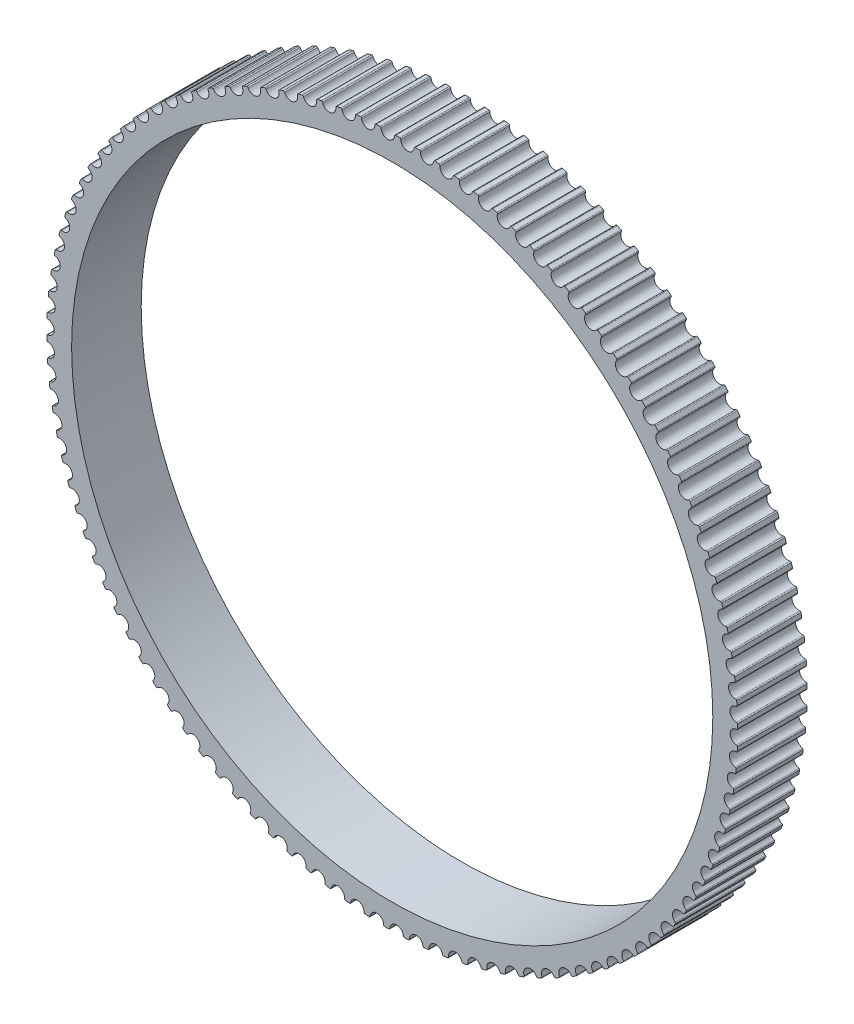
from build123d import *

# Parameters (mm, degrees)
BOSS_EXTRUDE1_DEPTH = 3.5
SKETCH4_R           = 32.25
CUT_EXTRUDE2_DEPTH  = 3.5


with BuildPart() as part:
    # Sketch2 → Boss-Extrude1 (new body, symmetric)
    with BuildSketch(Plane.XY):
        with BuildLine():
            ThreePointArc((-3.211333328, 34.601298216), (-3.132582306, 34.577768977), (-3.092122191, 34.506226488))
            ThreePointArc((-3.092122191, 34.506226488), (-2.370608918, 33.917255392), (-1.738041502, 34.600868455))
            ThreePointArc((-1.738041502, 34.600868455), (-1.707926922, 34.677343683), (-1.633214692, 34.711599067))
            ThreePointArc((-1.633214692, 34.711599067), (-1.432005901, 34.720481839), (-1.230749008, 34.728198296))
            ThreePointArc((-1.230749008, 34.728198296), (-1.153469677, 34.700211628), (-1.117159824, 34.626475997))
            ThreePointArc((-1.117159824, 34.626475997), (-0.430446923, 33.997275118), (0.240115498, 34.643660757))
            ThreePointArc((0.240115498, 34.643660757), (0.274546844, 34.718292057), (0.351092826, 34.748226341))
            ThreePointArc((0.351092826, 34.748226341), (0.552480572, 34.745607855), (0.75384976, 34.741822211))
            ThreePointArc((0.75384976, 34.741822211), (0.829405331, 34.709469401), (0.861446487, 34.63378114))
            ThreePointArc((0.861446487, 34.63378114), (1.5111191, 33.966402798), (2.217489291, 34.573452638))
            ThreePointArc((2.217489291, 34.573452638), (2.256125096, 34.645996578), (2.334255151, 34.671512123))
            ThreePointArc((2.334255151, 34.671512123), (2.535164969, 34.657400921), (2.735989626, 34.642125523))
            ThreePointArc((2.735989626, 34.642125523), (2.809574991, 34.6055121), (2.837242938, 34.528118086))
            ThreePointArc((2.837242938, 34.528118086), (3.447756167, 33.824739133), (4.187630095, 34.390473103))
            ThreePointArc((4.187630095, 34.390473103), (4.230344336, 34.460693059), (4.309803622, 34.481706639))
            ThreePointArc((4.309803622, 34.481706639), (4.509580184, 34.456148748), (4.709205264, 34.429433422))
            ThreePointArc((4.709205264, 34.429433422), (4.780580401, 34.388678811), (4.803784892, 34.309831489))
            ThreePointArc((4.803784892, 34.309831489), (5.373147369, 33.572746199), (6.14411172, 34.095318993))
            ThreePointArc((6.14411172, 34.095318993), (6.190765072, 34.162985922), (6.271294408, 34.179428995))
            ThreePointArc((6.271294408, 34.179428995), (6.469286087, 34.14250778), (6.667060452, 34.104439666))
            ThreePointArc((6.667060452, 34.104439666), (6.735992552, 34.059676799), (6.754657899, 33.979633352))
            ThreePointArc((6.754657899, 33.979633352), (7.281012482, 33.211245945), (8.080552529, 33.68895304))
            ThreePointArc((8.080552529, 33.68895304), (8.13099282, 33.753846226), (8.212329536, 33.765665158))
            ThreePointArc((8.212329536, 33.765665158), (8.407890523, 33.717501049), (8.603169075, 33.668204316))
            ThreePointArc((8.603169075, 33.668204316), (8.669433295, 33.619579201), (8.683498616, 33.538600714))
            ThreePointArc((8.683498616, 33.538600714), (9.165128446, 32.74141751), (9.990636256, 33.172700723))
            ThreePointArc((9.990636256, 33.172700723), (10.044698959, 33.2346085), (10.126577752, 33.24176474))
            ThreePointArc((10.126577752, 33.24176474), (10.319070167, 33.182514837), (10.511215949, 33.122150282))
            ThreePointArc((10.511215949, 33.122150282), (10.574596148, 33.069821524), (10.584015565, 32.988172132))
            ThreePointArc((10.584015565, 32.988172132), (11.019349666, 32.164793376), (11.868132604, 32.548245952))
            ThreePointArc((11.868132604, 32.548245952), (11.925641377, 32.606966388), (12.007795176, 32.609436594))
            ThreePointArc((12.007795176, 32.609436594), (12.196591149, 32.539294158), (12.384977421, 32.468058678))
            ThreePointArc((12.384977421, 32.468058678), (12.445266867, 32.412196962), (12.450009655, 32.330142989))
            ThreePointArc((12.450009655, 32.330142989), (12.837628057, 31.483254372), (13.70691757, 31.817625568))
            ThreePointArc((13.70691757, 31.817625568), (13.767684832, 31.87296713), (13.849845668, 31.870743245))
            ThreePointArc((13.849845668, 31.870743245), (14.034329387, 31.789937066), (14.21834167, 31.708063015))
            ThreePointArc((14.21834167, 31.708063015), (14.275343712, 31.648850551), (14.275394401, 31.566659639))
            ThreePointArc((14.275394401, 31.566659639), (14.614032774, 30.699023536), (15.50099342, 30.983222703))
            ThreePointArc((15.50099342, 30.983222703), (15.564820961, 31.035004878), (15.646720842, 31.028094155))
            ThreePointArc((15.646720842, 31.028094155), (15.826290558, 30.936887807), (16.005328645, 30.844642241))
            ThreePointArc((16.005328645, 30.844642241), (16.058857353, 30.782272168), (16.054215778, 30.700212407))
            ThreePointArc((16.054215778, 30.700212407), (16.342769554, 29.814658866), (17.244508252, 30.047759005))
            ThreePointArc((17.244508252, 30.047759005), (17.31118788, 30.09581289), (17.392559666, 30.084237871))
            ThreePointArc((17.392559666, 30.084237871), (17.56662966, 29.982928849), (17.740109564, 29.880612655))
            ThreePointArc((17.740109564, 29.880612655), (17.78999034, 29.815288411), (17.78067164, 29.733627463))
            ThreePointArc((17.78067164, 29.733627463), (18.018199616, 28.833044976), (18.931775082, 29.014285763))
            ThreePointArc((18.931775082, 29.014285763), (19.001089301, 29.058454616), (19.081667574, 29.042253056))
            ThreePointArc((19.081667574, 29.042253056), (19.249670067, 28.93117181), (19.417025934, 28.819118722))
            ThreePointArc((19.417025934, 28.819118722), (19.463096075, 28.75105338), (19.449130647, 28.670057606))
            ThreePointArc((19.449130647, 28.670057606), (19.634858056, 27.757383686), (20.557290396, 27.886173951))
            ThreePointArc((20.557290396, 27.886173951), (20.629013119, 27.926313703), (20.708535049, 27.905538449))
            ThreePointArc((20.708535049, 27.905538449), (20.869922051, 27.785047302), (21.030608, 27.663622813))
            ThreePointArc((21.030608, 27.663622813), (21.072717237, 27.59303839), (21.054150632, 27.512971981))
            ThreePointArc((21.054150632, 27.512971981), (21.187471671, 26.59118358), (22.115752103, 26.667103236))
            ThreePointArc((22.115752103, 26.667103236), (22.189649383, 26.70308296), (22.267855587, 26.677801775))
            ThreePointArc((22.267855587, 26.677801775), (22.422100687, 26.548293745), (22.575592595, 26.417893917))
            ThreePointArc((22.575592595, 26.417893917), (22.613603575, 26.345020643), (22.590496355, 26.26614476))
            ThreePointArc((22.590496355, 26.26614476), (22.670976156, 25.338248561), (23.602076822, 25.361049973))
            ThreePointArc((23.602076822, 25.361049973), (23.677907624, 25.39275231), (23.754543009, 25.363047657))
            ThreePointArc((23.754543009, 25.363047657), (23.901143092, 25.224945172), (24.046940299, 25.085995341))
            ThreePointArc((24.046940299, 25.085995341), (24.080729038, 25.011070915), (24.053156573, 24.933642834))
            ThreePointArc((24.053156573, 24.933642834), (24.08053263, 24.002665441), (25.011416473, 23.972274237))
            ThreePointArc((25.011416473, 23.972274237), (25.088933451, 23.99959578), (25.163748048, 23.965564549))
            ThreePointArc((25.163748048, 23.965564549), (25.302224935, 23.81931807), (25.439851882, 23.672271464))
            ThreePointArc((25.439851882, 23.672271464), (25.469308169, 23.595540272), (25.437360394, 23.519812547))
            ThreePointArc((25.437360394, 23.519812547), (25.411543411, 22.588790615), (26.339174082, 22.505305925))
            ThreePointArc((26.339174082, 22.505305925), (26.418124392, 22.528157557), (26.490874172, 22.489910751))
            ThreePointArc((26.490874172, 22.489910751), (26.62077618, 22.335997304), (26.749783955, 22.181333557))
            ThreePointArc((26.749783955, 22.181333557), (26.77481171, 22.103045881), (26.738592833, 22.029265521))
            ThreePointArc((26.738592833, 22.029265521), (26.65966702, 21.10123585), (27.58101878, 20.964929982))
            ThreePointArc((27.58101878, 20.964929982), (27.661144903, 20.983237166), (27.731592571, 20.940899539))
            ThreePointArc((27.731592571, 20.940899539), (27.852495986, 20.779821157), (27.972463794, 20.61804475))
            ThreePointArc((27.972463794, 20.61804475), (27.99298138, 20.538455949), (27.95260954, 20.466863609))
            ThreePointArc((27.95260954, 20.466863609), (27.820832336, 19.544853239), (28.732899927, 19.356170796))
            ThreePointArc((28.732899927, 19.356170796), (28.813940508, 19.369873818), (28.881856278, 19.323583465))
            ThreePointArc((28.881856278, 19.323583465), (28.99336674, 19.155865553), (29.103903269, 18.987504167))
            ThreePointArc((29.103903269, 18.987504167), (29.119843764, 18.906873842), (29.075450644, 18.837703042))
            ThreePointArc((29.075450644, 18.837703042), (28.89125188, 17.924719379), (29.791060327, 17.684275803))
            ThreePointArc((29.791060327, 17.684275803), (29.872751028, 17.693329967), (29.937913374, 17.643237878))
            ThreePointArc((29.937913374, 17.643237878), (30.039667157, 17.469427497), (30.140411862, 17.295030292))
            ThreePointArc((30.140411862, 17.295030292), (30.15172327, 17.213621443), (30.103453672, 17.147097804))
            ThreePointArc((30.103453672, 17.147097804), (29.867434165, 16.24611881), (30.75204848, 15.954698379))
            ThreePointArc((30.75204848, 15.954698379), (30.834122844, 15.959074151), (30.896319219, 15.905343716))
            ThreePointArc((30.896319219, 15.905343716), (30.987984424, 15.7260078), (31.078608696, 15.546143623))
            ThreePointArc((31.078608696, 15.546143623), (31.085254121, 15.464221788), (31.033265491, 15.400562296))
            ThreePointArc((31.033265491, 15.400562296), (30.746195088, 14.514526779), (31.612729843, 14.173080045))
            ThreePointArc((31.612729843, 14.173080045), (31.69492016, 14.172763152), (31.753947692, 14.115569629))
            ThreePointArc((31.753947692, 14.115569629), (31.835225327, 13.931293134), (31.915433568, 13.746548664))
            ThreePointArc((31.915433568, 13.746548664), (31.917391335, 13.664381057), (31.861853248, 13.603793356))
            ThreePointArc((31.861853248, 13.603793356), (31.524668313, 12.735591378), (32.370297052, 12.345232069))
            ThreePointArc((32.370297052, 12.345232069), (32.452335234, 12.340223546), (32.508001388, 12.279753488))
            ThreePointArc((32.508001388, 12.279753488), (32.578626342, 12.091137485), (32.648156929, 11.902115321))
            ThreePointArc((32.648156929, 11.902115321), (32.645420653, 11.819969954), (32.586514263, 11.762651669))
            ThreePointArc((32.586514263, 11.762651669), (32.200314623, 10.915115125), (33.02227908, 10.477116513))
            ThreePointArc((33.02227908, 10.477116513), (33.103897536, 10.467432696), (33.156020741, 10.403883344))
            ThreePointArc((33.156020741, 10.403883344), (33.215762649, 10.211543059), (33.274388789, 10.018859752))
            ThreePointArc((33.274388789, 10.018859752), (33.266967394, 9.937004566), (33.204884841, 9.883142657))
            ThreePointArc((33.204884841, 9.883142657), (32.770930199, 9.059036036), (33.566549298, 8.57482678))
            ThreePointArc((33.566549298, 8.57482678), (33.647481805, 8.560499256), (33.695892045, 8.494077894))
            ThreePointArc((33.695892045, 8.494077894), (33.744556042, 8.298640702), (33.792086508, 8.102924745))
            ThreePointArc((33.792086508, 8.102924745), (33.780004201, 8.021626735), (33.714947986, 7.971396888))
            ThreePointArc((33.714947986, 7.971396888), (33.234653812, 7.173408254), (34.001332409, 6.644567744))
            ThreePointArc((34.001332409, 6.644567744), (34.081314982, 6.625643246), (34.125854354, 6.556566528))
            ThreePointArc((34.125854354, 6.556566528), (34.163281708, 6.358669904), (34.199561465, 6.160559682))
            ThreePointArc((34.199561465, 6.160559682), (34.182857657, 6.080084025), (34.115039979, 6.033650079))
            ThreePointArc((34.115039979, 6.033650079), (33.589972893, 5.264382305), (34.32521024, 4.69263551))
            ThreePointArc((34.32521024, 4.69263551), (34.403981993, 4.669175766), (34.444505218, 4.597669005))
            ThreePointArc((34.444505218, 4.597669005), (34.470573849, 4.397958446), (34.495484561, 4.198100153))
            ThreePointArc((34.495484561, 4.198100153), (34.474213735, 4.118709344), (34.403855803, 4.076222758))
            ThreePointArc((34.403855803, 4.076222758), (33.835728464, 3.338185035), (34.537126371, 2.725396874))
            ThreePointArc((34.537126371, 2.725396874), (34.614430366, 2.697478404), (34.650805266, 2.623774841))
            ThreePointArc((34.650805266, 2.623774841), (34.665430144, 2.422901762), (34.678890556, 2.221947294))
            ThreePointArc((34.678890556, 2.221947294), (34.653122094, 2.143900289), (34.5804534, 2.105499646))
            ThreePointArc((34.5804534, 2.105499646), (33.971118921, 1.401099299), (34.636389574, 0.74926856))
            ThreePointArc((34.636389574, 0.74926856), (34.711973662, 0.716982429), (34.744081589, 0.641322469))
            ThreePointArc((34.744081589, 0.641322469), (34.74721501, 0.439942076), (34.749181219, 0.238546905))
            ThreePointArc((34.749181219, 0.238546905), (34.718999171, 0.162098278), (34.644256745, 0.127908831))
            ThreePointArc((34.644256745, 0.127908831), (33.99570265, -0.540556531), (34.622676073, -1.229303713))
            ThreePointArc((34.622676073, -1.229303713), (34.696293715, -1.265852194), (34.72402994, -1.343221764))
            ThreePointArc((34.72402994, -1.343221764), (34.715661684, -1.544452609), (34.706127275, -1.745631574))
            ThreePointArc((34.706127275, -1.745631574), (34.67163009, -1.820232465), (34.595057726, -1.850099196))
            ThreePointArc((34.595057726, -1.850099196), (33.909399462, -2.480449178), (34.496030599, -3.203866252))
            ThreePointArc((34.496030599, -3.203866252), (34.567441669, -3.24455787), (34.590715723, -3.323384687))
            ThreePointArc((34.590715723, -3.323384687), (34.570873084, -3.523809611), (34.549869157, -3.724116166))
            ThreePointArc((34.549869157, -3.724116166), (34.511169358, -3.796625987), (34.433016819, -3.822072584))
            ThreePointArc((34.433016819, -3.822072584), (33.712490862, -4.412251116), (34.256866244, -5.167978446))
            ThreePointArc((34.256866244, -5.167978446), (34.325837814, -5.212680473), (34.344573781, -5.292707419))
            ThreePointArc((34.344573781, -5.292707419), (34.313321483, -5.491672679), (34.280916548, -5.690453466))
            ThreePointArc((34.280916548, -5.690453466), (34.238140364, -5.760635705), (34.158662568, -5.781579165))
            ThreePointArc((34.158662568, -5.781579165), (33.405619123, -6.329661207), (33.905963111, -7.115233768))
            ThreePointArc((33.905963111, -7.115233768), (33.97227021, -7.163800395), (33.986406977, -7.24476644))
            ThreePointArc((33.986406977, -7.24476644), (33.943846959, -7.441623052), (33.900146714, -7.638229688))
            ThreePointArc((33.900146714, -7.638229688), (33.853433673, -7.705855426), (33.77288986, -7.722227437))
            ThreePointArc((33.77288986, -7.722227437), (32.989785199, -8.226425259), (33.444465774, -9.039280676))
            ThreePointArc((33.444465774, -9.039280676), (33.507892122, -9.09155349), (33.517383579, -9.173194539))
            ThreePointArc((33.517383579, -9.173194539), (33.463654661, -9.367300397), (33.408801648, -9.561091593))
            ThreePointArc((33.408801648, -9.561091593), (33.358304118, -9.625940249), (33.276957005, -9.637687408))
            ThreePointArc((33.276957005, -9.637687408), (32.466345452, -10.096356422), (32.873879542, -10.93384333))
            ThreePointArc((32.873879542, -10.93384333), (32.934218255, -10.989651827), (32.939033441, -11.071701583))
            ThreePointArc((32.939033441, -11.071701583), (32.874310877, -11.262423555), (32.808484015, -11.452767205))
            ThreePointArc((32.808484015, -11.452767205), (32.754366709, -11.514627255), (32.672481633, -11.521711246))
            ThreePointArc((32.672481633, -11.521711246), (31.837007234, -11.933355369), (32.196065547, -12.792742059))
            ThreePointArc((32.196065547, -12.792742059), (32.253119813, -12.851904204), (32.253243023, -12.934095039))
            ThreePointArc((32.253243023, -12.934095039), (32.177737925, -13.120811029), (32.101151926, -13.307086271))
            ThreePointArc((32.101151926, -13.307086271), (32.043591363, -13.365755941), (31.961435416, -13.368153657))
            ThreePointArc((31.961435416, -13.368153657), (31.103823316, -13.731430191), (31.413234678, -14.609913523))
            ThreePointArc((31.413234678, -14.609913523), (31.466818398, -14.67223634), (31.462249231, -14.754300165))
            ThreePointArc((31.462249231, -14.754300165), (31.376207879, -14.936401144), (31.289112552, -15.118000387))
            ThreePointArc((31.289112552, -15.118000387), (31.228296483, -15.173288309), (31.146137641, -15.170991929))
            ThreePointArc((31.146137641, -15.170991929), (30.269185192, -15.484715942), (30.527940367, -16.379430485))
            ThreePointArc((30.527940367, -16.379430485), (30.577878762, -16.444710691), (30.56863212, -16.52637983))
            ThreePointArc((30.56863212, -16.52637983), (30.472335165, -16.703271823), (30.375014597, -16.879602728))
            ThreePointArc((30.375014597, -16.879602728), (30.31114139, -16.931328564), (30.229247639, -16.924345579))
            ThreePointArc((30.229247639, -16.924345579), (29.335815277, -17.187493768), (29.54307026, -18.09552115))
            ThreePointArc((29.54307026, -18.09552115), (29.589200441, -18.163545815), (29.575306486, -18.24455388))
            ThreePointArc((29.575306486, -18.24455388), (29.469068027, -18.415659902), (29.361839657, -18.586147313))
            ThreePointArc((29.361839657, -18.586147313), (29.295117655, -18.634142344), (29.213756114, -18.622495531))
            ThreePointArc((29.213756114, -18.622495531), (28.30675803, -18.834209562), (28.461836798, -19.752587986))
            ThreePointArc((28.461836798, -19.752587986), (28.504008299, -19.823135227), (28.485512349, -19.903217987))
            ThreePointArc((28.485512349, -19.903217987), (28.369678915, -20.067979925), (28.252892499, -20.232067749))
            ThreePointArc((28.252892499, -20.232067749), (28.183539334, -20.276175426), (28.102975388, -20.259902774))
            ThreePointArc((28.102975388, -20.259902774), (27.185370022, -20.419492079), (27.287766741, -21.345225986))
            ThreePointArc((27.287766741, -21.345225986), (27.325842006, -21.418065692), (27.302804391, -21.496961933))
            ThreePointArc((27.302804391, -21.496961933), (27.177753806, -21.654842369), (27.051790279, -21.811995386))
            ThreePointArc((27.051790279, -21.811995386), (26.980032167, -21.852071837), (26.900528599, -21.831226424))
            ThreePointArc((26.900528599, -21.831226424), (25.975308988, -21.938170457), (26.02468966, -22.868240295))
            ThreePointArc((26.02468966, -22.868240295), (26.058544496, -22.943134878), (26.031040361, -23.020587258))
            ThreePointArc((26.031040361, -23.020587258), (25.897180514, -23.171071219), (25.762450741, -23.320776827))
            ThreePointArc((25.762450741, -23.320776827), (25.688521742, -23.356691333), (25.610337876, -23.331341152))
            ThreePointArc((25.610337876, -23.331341152), (24.680521894, -23.385291083), (24.676725451, -24.316663157))
            ThreePointArc((24.676725451, -24.316663157), (24.706249431, -24.393368328), (24.674368488, -24.469124213))
            ThreePointArc((24.674368488, -24.469124213), (24.532136002, -24.61172085), (24.389079444, -24.753490741))
            ThreePointArc((24.389079444, -24.753490741), (24.313220699, -24.785126155), (24.236611554, -24.755353895))
            ThreePointArc((24.236611554, -24.755353895), (23.305232069, -24.75613375), (23.248270892, -25.685770119))
            ThreePointArc((23.248270892, -25.685770119), (23.273367715, -25.76403568), (23.237213953, -25.83784797))
            ThreePointArc((23.237213953, -25.83784797), (23.087072761, -25.972092163), (22.936156039, -26.105463914))
            ThreePointArc((22.936156039, -26.105463914), (22.858614984, -26.132717049), (22.783830443, -26.098619818))
            ThreePointArc((22.783830443, -26.098619818), (21.85392542, -26.046227054), (21.743985306, -26.971095437))
            ThreePointArc((21.743985306, -26.971095437), (21.764573111, -27.050666103), (21.724264456, -27.122294037))
            ThreePointArc((21.724264456, -27.122294037), (21.566704287, -27.24774791), (21.40841966, -27.372286489))
            ThreePointArc((21.40841966, -27.372286489), (21.329449217, -27.39506845), (21.256733213, -27.356757468))
            ThreePointArc((21.256733213, -27.356757468), (20.331335809, -27.251362979), (20.16877536, -28.168446648))
            ThreePointArc((20.16877536, -28.168446648), (20.184786993, -28.249062876), (20.140454924, -28.318272819))
            ThreePointArc((20.140454924, -28.318272819), (19.975989707, -28.434527167), (19.810853466, -28.549826356))
            ThreePointArc((19.810853466, -28.549826356), (19.730711221, -28.568062833), (19.660300937, -28.525663062))
            ThreePointArc((19.660300937, -28.525663062), (18.742429606, -28.367610623), (18.527779061, -29.273918241))
            ThreePointArc((18.527779061, -29.273918241), (18.539162295, -29.355317077), (18.490951414, -29.421883281))
            ThreePointArc((18.490951414, -29.421883281), (18.320117601, -29.528558907), (18.148668386, -29.634242622))
            ThreePointArc((18.148668386, -29.634242622), (18.067615746, -29.647874132), (17.999740847, -29.601523872))
            ThreePointArc((17.999740847, -29.601523872), (17.092389494, -29.391329017), (16.826348997, -30.283904397))
            ThreePointArc((16.826348997, -30.283904397), (16.833066704, -30.365820336), (16.781134264, -30.429525675))
            ThreePointArc((16.781134264, -30.429525675), (16.604489078, -30.526274624), (16.427286122, -30.621998149))
            ThreePointArc((16.427286122, -30.621998149), (16.345587463, -30.630980229), (16.280469342, -30.580830663))
            ThreePointArc((16.280469342, -30.580830663), (15.38659756, -30.319179005), (15.07003488, -31.195110751))
            ThreePointArc((15.07003488, -31.195110751), (15.072065148, -31.2772766), (15.016580542, -31.337913281))
            ThreePointArc((15.016580542, -31.337913281), (14.834700164, -31.42441998), (14.652321465, -31.509871083))
            ThreePointArc((14.652321465, -31.509871083), (14.570243272, -31.514174435), (14.508094331, -31.460389142))
            ThreePointArc((14.508094331, -31.460389142), (13.630617742, -31.148134133), (13.264565442, -32.004565139))
            ThreePointArc((13.264565442, -32.004565139), (13.261901648, -32.086712889), (13.203045856, -32.144083128))
            ThreePointArc((13.203045856, -32.144083128), (13.016523541, -32.220065408), (12.829563981, -32.294965367))
            ThreePointArc((12.829563981, -32.294965367), (12.747373976, -32.294575954), (12.688396932, -32.23733037))
            ThreePointArc((12.688396932, -32.23733037), (11.830177683, -31.875490522), (11.415829748, -32.709627287))
            ThreePointArc((11.415829748, -32.709627287), (11.408480581, -32.791488989), (11.346445578, -32.845405657))
            ThreePointArc((11.346445578, -32.845405657), (11.155889724, -32.910615681), (10.964959126, -32.974720186))
            ThreePointArc((10.964959126, -32.974720186), (10.882925395, -32.969639279), (10.827312619, -32.909120127))
            ThreePointArc((10.827312619, -32.909120127), (9.991150043, -32.498875685), (9.529857991, -33.307997429))
            ThreePointArc((9.529857991, -33.307997429), (9.517847422, -33.389306069), (9.452835553, -33.439593299))
            ThreePointArc((9.452835553, -33.439593299), (9.258867713, -33.493818365), (9.064588853, -33.546918322))
            ThreePointArc((9.064588853, -33.546918322), (8.982978974, -33.537162493), (8.930911862, -33.473567174))
            ThreePointArc((8.930911862, -33.473567174), (8.119533349, -33.016256272), (7.612801817, -33.797723808))
            ThreePointArc((7.612801817, -33.797723808), (7.596169023, -33.878214172), (7.528392344, -33.924707939))
            ThreePointArc((7.528392344, -33.924707939), (7.3316452, -33.967771176), (7.134651776, -34.009693384))
            ThreePointArc((7.134651776, -34.009693384), (7.053731942, -33.995294454), (7.005380328, -33.928830403))
            ThreePointArc((7.005380328, -33.928830403), (6.221432424, -33.425944693), (5.670914266, -34.177209036))
            ThreePointArc((5.670914266, -34.177209036), (5.6497135, -34.256618582), (5.579393083, -34.299167232))
            ThreePointArc((5.579393083, -34.299167232), (5.380508385, -34.330928177), (5.181442947, -34.361535894))
            ThreePointArc((5.181442947, -34.361535894), (5.101477103, -34.34254083), (5.056998699, -34.27342484))
            ThreePointArc((5.056998699, -34.27342484), (4.30303848, -33.72660463), (3.710529372, -34.445215311))
            ThreePointArc((3.710529372, -34.445215311), (3.684829785, -34.523285023), (3.612195002, -34.561749771))
            ThreePointArc((3.612195002, -34.561749771), (3.411821469, -34.582104827), (3.211333328, -34.601298216))
            ThreePointArc((3.211333328, -34.601298216), (3.132582306, -34.577768977), (3.092122191, -34.506226488))
            ThreePointArc((3.092122191, -34.506226488), (2.370608918, -33.917255392), (1.738041502, -34.600868455))
            ThreePointArc((1.738041502, -34.600868455), (1.707926922, -34.677343683), (1.633214692, -34.711599067))
            ThreePointArc((1.633214692, -34.711599067), (1.432005901, -34.720481839), (1.230749008, -34.728198296))
            ThreePointArc((1.230749008, -34.728198296), (1.153469677, -34.700211628), (1.117159824, -34.626475997))
            ThreePointArc((1.117159824, -34.626475997), (0.430446923, -33.997275118), (-0.240115498, -34.643660757))
            ThreePointArc((-0.240115498, -34.643660757), (-0.274546844, -34.718292057), (-0.351092826, -34.748226341))
            ThreePointArc((-0.351092826, -34.748226341), (-0.552480572, -34.745607855), (-0.75384976, -34.741822211))
            ThreePointArc((-0.75384976, -34.741822211), (-0.829405331, -34.709469401), (-0.861446487, -34.63378114))
            ThreePointArc((-0.861446487, -34.63378114), (-1.5111191, -33.966402798), (-2.217489291, -34.573452638))
            ThreePointArc((-2.217489291, -34.573452638), (-2.256125096, -34.645996578), (-2.334255151, -34.671512123))
            ThreePointArc((-2.334255151, -34.671512123), (-2.535164969, -34.657400921), (-2.735989626, -34.642125523))
            ThreePointArc((-2.735989626, -34.642125523), (-2.809574991, -34.6055121), (-2.837242938, -34.528118086))
            ThreePointArc((-2.837242938, -34.528118086), (-3.447756167, -33.824739133), (-4.187630095, -34.390473103))
            ThreePointArc((-4.187630095, -34.390473103), (-4.230344336, -34.460693059), (-4.309803622, -34.481706639))
            ThreePointArc((-4.309803622, -34.481706639), (-4.509580184, -34.456148748), (-4.709205264, -34.429433422))
            ThreePointArc((-4.709205264, -34.429433422), (-4.780580401, -34.388678811), (-4.803784892, -34.309831489))
            ThreePointArc((-4.803784892, -34.309831489), (-5.373147369, -33.572746199), (-6.14411172, -34.095318993))
            ThreePointArc((-6.14411172, -34.095318993), (-6.190765072, -34.162985922), (-6.271294408, -34.179428995))
            ThreePointArc((-6.271294408, -34.179428995), (-6.469286087, -34.14250778), (-6.667060452, -34.104439666))
            ThreePointArc((-6.667060452, -34.104439666), (-6.735992552, -34.059676799), (-6.754657899, -33.979633352))
            ThreePointArc((-6.754657899, -33.979633352), (-7.281012482, -33.211245945), (-8.080552529, -33.68895304))
            ThreePointArc((-8.080552529, -33.68895304), (-8.13099282, -33.753846226), (-8.212329536, -33.765665158))
            ThreePointArc((-8.212329536, -33.765665158), (-8.407890523, -33.717501049), (-8.603169075, -33.668204316))
            ThreePointArc((-8.603169075, -33.668204316), (-8.669433295, -33.619579201), (-8.683498616, -33.538600714))
            ThreePointArc((-8.683498616, -33.538600714), (-9.165128446, -32.74141751), (-9.990636256, -33.172700723))
            ThreePointArc((-9.990636256, -33.172700723), (-10.044698959, -33.2346085), (-10.126577752, -33.24176474))
            ThreePointArc((-10.126577752, -33.24176474), (-10.319070167, -33.182514837), (-10.511215949, -33.122150282))
            ThreePointArc((-10.511215949, -33.122150282), (-10.574596148, -33.069821524), (-10.584015565, -32.988172132))
            ThreePointArc((-10.584015565, -32.988172132), (-11.019349666, -32.164793376), (-11.868132604, -32.548245952))
            ThreePointArc((-11.868132604, -32.548245952), (-11.925641377, -32.606966388), (-12.007795176, -32.609436594))
            ThreePointArc((-12.007795176, -32.609436594), (-12.196591149, -32.539294158), (-12.384977421, -32.468058678))
            ThreePointArc((-12.384977421, -32.468058678), (-12.445266867, -32.412196962), (-12.450009655, -32.330142989))
            ThreePointArc((-12.450009655, -32.330142989), (-12.837628057, -31.483254372), (-13.70691757, -31.817625568))
            ThreePointArc((-13.70691757, -31.817625568), (-13.767684832, -31.87296713), (-13.849845668, -31.870743245))
            ThreePointArc((-13.849845668, -31.870743245), (-14.034329387, -31.789937066), (-14.21834167, -31.708063015))
            ThreePointArc((-14.21834167, -31.708063015), (-14.275343712, -31.648850551), (-14.275394401, -31.566659639))
            ThreePointArc((-14.275394401, -31.566659639), (-14.614032774, -30.699023536), (-15.50099342, -30.983222703))
            ThreePointArc((-15.50099342, -30.983222703), (-15.564820961, -31.035004878), (-15.646720842, -31.028094155))
            ThreePointArc((-15.646720842, -31.028094155), (-15.826290558, -30.936887807), (-16.005328645, -30.844642241))
            ThreePointArc((-16.005328645, -30.844642241), (-16.058857353, -30.782272168), (-16.054215778, -30.700212407))
            ThreePointArc((-16.054215778, -30.700212407), (-16.342769554, -29.814658866), (-17.244508252, -30.047759005))
            ThreePointArc((-17.244508252, -30.047759005), (-17.31118788, -30.09581289), (-17.392559666, -30.084237871))
            ThreePointArc((-17.392559666, -30.084237871), (-17.56662966, -29.982928849), (-17.740109564, -29.880612655))
            ThreePointArc((-17.740109564, -29.880612655), (-17.78999034, -29.815288411), (-17.78067164, -29.733627463))
            ThreePointArc((-17.78067164, -29.733627463), (-18.018199616, -28.833044976), (-18.931775082, -29.014285763))
            ThreePointArc((-18.931775082, -29.014285763), (-19.001089301, -29.058454616), (-19.081667574, -29.042253056))
            ThreePointArc((-19.081667574, -29.042253056), (-19.249670067, -28.93117181), (-19.417025934, -28.819118722))
            ThreePointArc((-19.417025934, -28.819118722), (-19.463096075, -28.75105338), (-19.449130647, -28.670057606))
            ThreePointArc((-19.449130647, -28.670057606), (-19.634858056, -27.757383686), (-20.557290396, -27.886173951))
            ThreePointArc((-20.557290396, -27.886173951), (-20.629013119, -27.926313703), (-20.708535049, -27.905538449))
            ThreePointArc((-20.708535049, -27.905538449), (-20.869922051, -27.785047302), (-21.030608, -27.663622813))
            ThreePointArc((-21.030608, -27.663622813), (-21.072717237, -27.59303839), (-21.054150632, -27.512971981))
            ThreePointArc((-21.054150632, -27.512971981), (-21.187471671, -26.59118358), (-22.115752103, -26.667103236))
            ThreePointArc((-22.115752103, -26.667103236), (-22.189649383, -26.70308296), (-22.267855587, -26.677801775))
            ThreePointArc((-22.267855587, -26.677801775), (-22.422100687, -26.548293745), (-22.575592595, -26.417893917))
            ThreePointArc((-22.575592595, -26.417893917), (-22.613603575, -26.345020643), (-22.590496355, -26.26614476))
            ThreePointArc((-22.590496355, -26.26614476), (-22.670976156, -25.338248561), (-23.602076822, -25.361049973))
            ThreePointArc((-23.602076822, -25.361049973), (-23.677907624, -25.39275231), (-23.754543009, -25.363047657))
            ThreePointArc((-23.754543009, -25.363047657), (-23.901143092, -25.224945172), (-24.046940299, -25.085995341))
            ThreePointArc((-24.046940299, -25.085995341), (-24.080729038, -25.011070915), (-24.053156573, -24.933642834))
            ThreePointArc((-24.053156573, -24.933642834), (-24.08053263, -24.002665441), (-25.011416473, -23.972274237))
            ThreePointArc((-25.011416473, -23.972274237), (-25.088933451, -23.99959578), (-25.163748048, -23.965564549))
            ThreePointArc((-25.163748048, -23.965564549), (-25.302224935, -23.81931807), (-25.439851882, -23.672271464))
            ThreePointArc((-25.439851882, -23.672271464), (-25.469308169, -23.595540272), (-25.437360394, -23.519812547))
            ThreePointArc((-25.437360394, -23.519812547), (-25.411543411, -22.588790615), (-26.339174082, -22.505305925))
            ThreePointArc((-26.339174082, -22.505305925), (-26.418124392, -22.528157557), (-26.490874172, -22.489910751))
            ThreePointArc((-26.490874172, -22.489910751), (-26.62077618, -22.335997304), (-26.749783955, -22.181333557))
            ThreePointArc((-26.749783955, -22.181333557), (-26.77481171, -22.103045881), (-26.738592833, -22.029265521))
            ThreePointArc((-26.738592833, -22.029265521), (-26.65966702, -21.10123585), (-27.58101878, -20.964929982))
            ThreePointArc((-27.58101878, -20.964929982), (-27.661144903, -20.983237166), (-27.731592571, -20.940899539))
            ThreePointArc((-27.731592571, -20.940899539), (-27.852495986, -20.779821157), (-27.972463794, -20.61804475))
            ThreePointArc((-27.972463794, -20.61804475), (-27.99298138, -20.538455949), (-27.95260954, -20.466863609))
            ThreePointArc((-27.95260954, -20.466863609), (-27.820832336, -19.544853239), (-28.732899927, -19.356170796))
            ThreePointArc((-28.732899927, -19.356170796), (-28.813940508, -19.369873818), (-28.881856278, -19.323583465))
            ThreePointArc((-28.881856278, -19.323583465), (-28.99336674, -19.155865553), (-29.103903269, -18.987504167))
            ThreePointArc((-29.103903269, -18.987504167), (-29.119843764, -18.906873842), (-29.075450644, -18.837703042))
            ThreePointArc((-29.075450644, -18.837703042), (-28.89125188, -17.924719379), (-29.791060327, -17.684275803))
            ThreePointArc((-29.791060327, -17.684275803), (-29.872751028, -17.693329967), (-29.937913374, -17.643237878))
            ThreePointArc((-29.937913374, -17.643237878), (-30.039667157, -17.469427497), (-30.140411862, -17.295030292))
            ThreePointArc((-30.140411862, -17.295030292), (-30.15172327, -17.213621443), (-30.103453672, -17.147097804))
            ThreePointArc((-30.103453672, -17.147097804), (-29.867434165, -16.24611881), (-30.75204848, -15.954698379))
            ThreePointArc((-30.75204848, -15.954698379), (-30.834122844, -15.959074151), (-30.896319219, -15.905343716))
            ThreePointArc((-30.896319219, -15.905343716), (-30.987984424, -15.7260078), (-31.078608696, -15.546143623))
            ThreePointArc((-31.078608696, -15.546143623), (-31.085254121, -15.464221788), (-31.033265491, -15.400562296))
            ThreePointArc((-31.033265491, -15.400562296), (-30.746195088, -14.514526779), (-31.612729843, -14.173080045))
            ThreePointArc((-31.612729843, -14.173080045), (-31.69492016, -14.172763152), (-31.753947692, -14.115569629))
            ThreePointArc((-31.753947692, -14.115569629), (-31.835225327, -13.931293134), (-31.915433568, -13.746548664))
            ThreePointArc((-31.915433568, -13.746548664), (-31.917391335, -13.664381057), (-31.861853248, -13.603793356))
            ThreePointArc((-31.861853248, -13.603793356), (-31.524668313, -12.735591378), (-32.370297052, -12.345232069))
            ThreePointArc((-32.370297052, -12.345232069), (-32.452335234, -12.340223546), (-32.508001388, -12.279753488))
            ThreePointArc((-32.508001388, -12.279753488), (-32.578626342, -12.091137485), (-32.648156929, -11.902115321))
            ThreePointArc((-32.648156929, -11.902115321), (-32.645420653, -11.819969954), (-32.586514263, -11.762651669))
            ThreePointArc((-32.586514263, -11.762651669), (-32.200314623, -10.915115125), (-33.02227908, -10.477116513))
            ThreePointArc((-33.02227908, -10.477116513), (-33.103897536, -10.467432696), (-33.156020741, -10.403883344))
            ThreePointArc((-33.156020741, -10.403883344), (-33.215762649, -10.211543059), (-33.274388789, -10.018859752))
            ThreePointArc((-33.274388789, -10.018859752), (-33.266967394, -9.937004566), (-33.204884841, -9.883142657))
            ThreePointArc((-33.204884841, -9.883142657), (-32.770930199, -9.059036036), (-33.566549298, -8.57482678))
            ThreePointArc((-33.566549298, -8.57482678), (-33.647481805, -8.560499256), (-33.695892045, -8.494077894))
            ThreePointArc((-33.695892045, -8.494077894), (-33.744556042, -8.298640702), (-33.792086508, -8.102924745))
            ThreePointArc((-33.792086508, -8.102924745), (-33.780004201, -8.021626735), (-33.714947986, -7.971396888))
            ThreePointArc((-33.714947986, -7.971396888), (-33.234653812, -7.173408254), (-34.001332409, -6.644567744))
            ThreePointArc((-34.001332409, -6.644567744), (-34.081314982, -6.625643246), (-34.125854354, -6.556566528))
            ThreePointArc((-34.125854354, -6.556566528), (-34.163281708, -6.358669904), (-34.199561465, -6.160559682))
            ThreePointArc((-34.199561465, -6.160559682), (-34.182857657, -6.080084025), (-34.115039979, -6.033650079))
            ThreePointArc((-34.115039979, -6.033650079), (-33.589972893, -5.264382305), (-34.32521024, -4.69263551))
            ThreePointArc((-34.32521024, -4.69263551), (-34.403981993, -4.669175766), (-34.444505218, -4.597669005))
            ThreePointArc((-34.444505218, -4.597669005), (-34.470573849, -4.397958446), (-34.495484561, -4.198100153))
            ThreePointArc((-34.495484561, -4.198100153), (-34.474213735, -4.118709344), (-34.403855803, -4.076222758))
            ThreePointArc((-34.403855803, -4.076222758), (-33.835728464, -3.338185035), (-34.537126371, -2.725396874))
            ThreePointArc((-34.537126371, -2.725396874), (-34.614430366, -2.697478404), (-34.650805266, -2.623774841))
            ThreePointArc((-34.650805266, -2.623774841), (-34.665430144, -2.422901762), (-34.678890556, -2.221947294))
            ThreePointArc((-34.678890556, -2.221947294), (-34.653122094, -2.143900289), (-34.5804534, -2.105499646))
            ThreePointArc((-34.5804534, -2.105499646), (-33.971118921, -1.401099299), (-34.636389574, -0.74926856))
            ThreePointArc((-34.636389574, -0.74926856), (-34.711973662, -0.716982429), (-34.744081589, -0.641322469))
            ThreePointArc((-34.744081589, -0.641322469), (-34.74721501, -0.439942076), (-34.749181219, -0.238546905))
            ThreePointArc((-34.749181219, -0.238546905), (-34.718999171, -0.162098278), (-34.644256745, -0.127908831))
            ThreePointArc((-34.644256745, -0.127908831), (-33.99570265, 0.540556531), (-34.622676073, 1.229303713))
            ThreePointArc((-34.622676073, 1.229303713), (-34.696293715, 1.265852194), (-34.72402994, 1.343221764))
            ThreePointArc((-34.72402994, 1.343221764), (-34.715661684, 1.544452609), (-34.706127275, 1.745631574))
            ThreePointArc((-34.706127275, 1.745631574), (-34.67163009, 1.820232465), (-34.595057726, 1.850099196))
            ThreePointArc((-34.595057726, 1.850099196), (-33.909399462, 2.480449178), (-34.496030599, 3.203866252))
            ThreePointArc((-34.496030599, 3.203866252), (-34.567441669, 3.24455787), (-34.590715723, 3.323384687))
            ThreePointArc((-34.590715723, 3.323384687), (-34.570873084, 3.523809611), (-34.549869157, 3.724116166))
            ThreePointArc((-34.549869157, 3.724116166), (-34.511169358, 3.796625987), (-34.433016819, 3.822072584))
            ThreePointArc((-34.433016819, 3.822072584), (-33.712490862, 4.412251116), (-34.256866244, 5.167978446))
            ThreePointArc((-34.256866244, 5.167978446), (-34.325837814, 5.212680473), (-34.344573781, 5.292707419))
            ThreePointArc((-34.344573781, 5.292707419), (-34.313321483, 5.491672679), (-34.280916548, 5.690453466))
            ThreePointArc((-34.280916548, 5.690453466), (-34.238140364, 5.760635705), (-34.158662568, 5.781579165))
            ThreePointArc((-34.158662568, 5.781579165), (-33.405619123, 6.329661207), (-33.905963111, 7.115233768))
            ThreePointArc((-33.905963111, 7.115233768), (-33.97227021, 7.163800395), (-33.986406977, 7.24476644))
            ThreePointArc((-33.986406977, 7.24476644), (-33.943846959, 7.441623052), (-33.900146714, 7.638229688))
            ThreePointArc((-33.900146714, 7.638229688), (-33.853433673, 7.705855426), (-33.77288986, 7.722227437))
            ThreePointArc((-33.77288986, 7.722227437), (-32.989785199, 8.226425259), (-33.444465774, 9.039280676))
            ThreePointArc((-33.444465774, 9.039280676), (-33.507892122, 9.09155349), (-33.517383579, 9.173194539))
            ThreePointArc((-33.517383579, 9.173194539), (-33.463654661, 9.367300397), (-33.408801648, 9.561091593))
            ThreePointArc((-33.408801648, 9.561091593), (-33.358304118, 9.625940249), (-33.276957005, 9.637687408))
            ThreePointArc((-33.276957005, 9.637687408), (-32.466345452, 10.096356422), (-32.873879542, 10.93384333))
            ThreePointArc((-32.873879542, 10.93384333), (-32.934218255, 10.989651827), (-32.939033441, 11.071701583))
            ThreePointArc((-32.939033441, 11.071701583), (-32.874310877, 11.262423555), (-32.808484015, 11.452767205))
            ThreePointArc((-32.808484015, 11.452767205), (-32.754366709, 11.514627255), (-32.672481633, 11.521711246))
            ThreePointArc((-32.672481633, 11.521711246), (-31.837007234, 11.933355369), (-32.196065547, 12.792742059))
            ThreePointArc((-32.196065547, 12.792742059), (-32.253119813, 12.851904204), (-32.253243023, 12.934095039))
            ThreePointArc((-32.253243023, 12.934095039), (-32.177737925, 13.120811029), (-32.101151926, 13.307086271))
            ThreePointArc((-32.101151926, 13.307086271), (-32.043591363, 13.365755941), (-31.961435416, 13.368153657))
            ThreePointArc((-31.961435416, 13.368153657), (-31.103823316, 13.731430191), (-31.413234678, 14.609913523))
            ThreePointArc((-31.413234678, 14.609913523), (-31.466818398, 14.67223634), (-31.462249231, 14.754300165))
            ThreePointArc((-31.462249231, 14.754300165), (-31.376207879, 14.936401144), (-31.289112552, 15.118000387))
            ThreePointArc((-31.289112552, 15.118000387), (-31.228296483, 15.173288309), (-31.146137641, 15.170991929))
            ThreePointArc((-31.146137641, 15.170991929), (-30.269185192, 15.484715942), (-30.527940367, 16.379430485))
            ThreePointArc((-30.527940367, 16.379430485), (-30.577878762, 16.444710691), (-30.56863212, 16.52637983))
            ThreePointArc((-30.56863212, 16.52637983), (-30.472335165, 16.703271823), (-30.375014597, 16.879602728))
            ThreePointArc((-30.375014597, 16.879602728), (-30.31114139, 16.931328564), (-30.229247639, 16.924345579))
            ThreePointArc((-30.229247639, 16.924345579), (-29.335815277, 17.187493768), (-29.54307026, 18.09552115))
            ThreePointArc((-29.54307026, 18.09552115), (-29.589200441, 18.163545815), (-29.575306486, 18.24455388))
            ThreePointArc((-29.575306486, 18.24455388), (-29.469068027, 18.415659902), (-29.361839657, 18.586147313))
            ThreePointArc((-29.361839657, 18.586147313), (-29.295117655, 18.634142344), (-29.213756114, 18.622495531))
            ThreePointArc((-29.213756114, 18.622495531), (-28.30675803, 18.834209562), (-28.461836798, 19.752587986))
            ThreePointArc((-28.461836798, 19.752587986), (-28.504008299, 19.823135227), (-28.485512349, 19.903217987))
            ThreePointArc((-28.485512349, 19.903217987), (-28.369678915, 20.067979925), (-28.252892499, 20.232067749))
            ThreePointArc((-28.252892499, 20.232067749), (-28.183539334, 20.276175426), (-28.102975388, 20.259902774))
            ThreePointArc((-28.102975388, 20.259902774), (-27.185370022, 20.419492079), (-27.287766741, 21.345225986))
            ThreePointArc((-27.287766741, 21.345225986), (-27.325842006, 21.418065692), (-27.302804391, 21.496961933))
            ThreePointArc((-27.302804391, 21.496961933), (-27.177753806, 21.654842369), (-27.051790279, 21.811995386))
            ThreePointArc((-27.051790279, 21.811995386), (-26.980032167, 21.852071837), (-26.900528599, 21.831226424))
            ThreePointArc((-26.900528599, 21.831226424), (-25.975308988, 21.938170457), (-26.02468966, 22.868240295))
            ThreePointArc((-26.02468966, 22.868240295), (-26.058544496, 22.943134878), (-26.031040361, 23.020587258))
            ThreePointArc((-26.031040361, 23.020587258), (-25.897180514, 23.171071219), (-25.762450741, 23.320776827))
            ThreePointArc((-25.762450741, 23.320776827), (-25.688521742, 23.356691333), (-25.610337876, 23.331341152))
            ThreePointArc((-25.610337876, 23.331341152), (-24.680521894, 23.385291083), (-24.676725451, 24.316663157))
            ThreePointArc((-24.676725451, 24.316663157), (-24.706249431, 24.393368328), (-24.674368488, 24.469124213))
            ThreePointArc((-24.674368488, 24.469124213), (-24.532136002, 24.61172085), (-24.389079444, 24.753490741))
            ThreePointArc((-24.389079444, 24.753490741), (-24.313220699, 24.785126155), (-24.236611554, 24.755353895))
            ThreePointArc((-24.236611554, 24.755353895), (-23.305232069, 24.75613375), (-23.248270892, 25.685770119))
            ThreePointArc((-23.248270892, 25.685770119), (-23.273367715, 25.76403568), (-23.237213953, 25.83784797))
            ThreePointArc((-23.237213953, 25.83784797), (-23.087072761, 25.972092163), (-22.936156039, 26.105463914))
            ThreePointArc((-22.936156039, 26.105463914), (-22.858614984, 26.132717049), (-22.783830443, 26.098619818))
            ThreePointArc((-22.783830443, 26.098619818), (-21.85392542, 26.046227054), (-21.743985306, 26.971095437))
            ThreePointArc((-21.743985306, 26.971095437), (-21.764573111, 27.050666103), (-21.724264456, 27.122294037))
            ThreePointArc((-21.724264456, 27.122294037), (-21.566704287, 27.24774791), (-21.40841966, 27.372286489))
            ThreePointArc((-21.40841966, 27.372286489), (-21.329449217, 27.39506845), (-21.256733213, 27.356757468))
            ThreePointArc((-21.256733213, 27.356757468), (-20.331335809, 27.251362979), (-20.16877536, 28.168446648))
            ThreePointArc((-20.16877536, 28.168446648), (-20.184786993, 28.249062876), (-20.140454924, 28.318272819))
            ThreePointArc((-20.140454924, 28.318272819), (-19.975989707, 28.434527167), (-19.810853466, 28.549826356))
            ThreePointArc((-19.810853466, 28.549826356), (-19.730711221, 28.568062833), (-19.660300937, 28.525663062))
            ThreePointArc((-19.660300937, 28.525663062), (-18.742429606, 28.367610623), (-18.527779061, 29.273918241))
            ThreePointArc((-18.527779061, 29.273918241), (-18.539162295, 29.355317077), (-18.490951414, 29.421883281))
            ThreePointArc((-18.490951414, 29.421883281), (-18.320117601, 29.528558907), (-18.148668386, 29.634242622))
            ThreePointArc((-18.148668386, 29.634242622), (-18.067615746, 29.647874132), (-17.999740847, 29.601523872))
            ThreePointArc((-17.999740847, 29.601523872), (-17.092389494, 29.391329017), (-16.826348997, 30.283904397))
            ThreePointArc((-16.826348997, 30.283904397), (-16.833066704, 30.365820336), (-16.781134264, 30.429525675))
            ThreePointArc((-16.781134264, 30.429525675), (-16.604489078, 30.526274624), (-16.427286122, 30.621998149))
            ThreePointArc((-16.427286122, 30.621998149), (-16.345587463, 30.630980229), (-16.280469342, 30.580830663))
            ThreePointArc((-16.280469342, 30.580830663), (-15.38659756, 30.319179005), (-15.07003488, 31.195110751))
            ThreePointArc((-15.07003488, 31.195110751), (-15.072065148, 31.2772766), (-15.016580542, 31.337913281))
            ThreePointArc((-15.016580542, 31.337913281), (-14.834700164, 31.42441998), (-14.652321465, 31.509871083))
            ThreePointArc((-14.652321465, 31.509871083), (-14.570243272, 31.514174435), (-14.508094331, 31.460389142))
            ThreePointArc((-14.508094331, 31.460389142), (-13.630617742, 31.148134133), (-13.264565442, 32.004565139))
            ThreePointArc((-13.264565442, 32.004565139), (-13.261901648, 32.086712889), (-13.203045856, 32.144083128))
            ThreePointArc((-13.203045856, 32.144083128), (-13.016523541, 32.220065408), (-12.829563981, 32.294965367))
            ThreePointArc((-12.829563981, 32.294965367), (-12.747373976, 32.294575954), (-12.688396932, 32.23733037))
            ThreePointArc((-12.688396932, 32.23733037), (-11.830177683, 31.875490522), (-11.415829748, 32.709627287))
            ThreePointArc((-11.415829748, 32.709627287), (-11.408480581, 32.791488989), (-11.346445578, 32.845405657))
            ThreePointArc((-11.346445578, 32.845405657), (-11.155889724, 32.910615681), (-10.964959126, 32.974720186))
            ThreePointArc((-10.964959126, 32.974720186), (-10.882925395, 32.969639279), (-10.827312619, 32.909120127))
            ThreePointArc((-10.827312619, 32.909120127), (-9.991150043, 32.498875685), (-9.529857991, 33.307997429))
            ThreePointArc((-9.529857991, 33.307997429), (-9.517847422, 33.389306069), (-9.452835553, 33.439593299))
            ThreePointArc((-9.452835553, 33.439593299), (-9.258867713, 33.493818365), (-9.064588853, 33.546918322))
            ThreePointArc((-9.064588853, 33.546918322), (-8.982978974, 33.537162493), (-8.930911862, 33.473567174))
            ThreePointArc((-8.930911862, 33.473567174), (-8.119533349, 33.016256272), (-7.612801817, 33.797723808))
            ThreePointArc((-7.612801817, 33.797723808), (-7.596169023, 33.878214172), (-7.528392344, 33.924707939))
            ThreePointArc((-7.528392344, 33.924707939), (-7.3316452, 33.967771176), (-7.134651776, 34.009693384))
            ThreePointArc((-7.134651776, 34.009693384), (-7.053731942, 33.995294454), (-7.005380328, 33.928830403))
            ThreePointArc((-7.005380328, 33.928830403), (-6.221432424, 33.425944693), (-5.670914266, 34.177209036))
            ThreePointArc((-5.670914266, 34.177209036), (-5.6497135, 34.256618582), (-5.579393083, 34.299167232))
            ThreePointArc((-5.579393083, 34.299167232), (-5.380508385, 34.330928177), (-5.181442947, 34.361535894))
            ThreePointArc((-5.181442947, 34.361535894), (-5.101477103, 34.34254083), (-5.056998699, 34.27342484))
            ThreePointArc((-5.056998699, 34.27342484), (-4.30303848, 33.72660463), (-3.710529372, 34.445215311))
            ThreePointArc((-3.710529372, 34.445215311), (-3.684829785, 34.523285023), (-3.612195002, 34.561749771))
            ThreePointArc((-3.612195002, 34.561749771), (-3.411821469, 34.582104827), (-3.211333328, 34.601298216))
        make_face()
    extrude(amount=BOSS_EXTRUDE1_DEPTH, both=True)

    # Sketch4 → Cut-Extrude2 (cut, symmetric)
    with BuildSketch(Plane.XY):
        Circle(SKETCH4_R)
    extrude(amount=CUT_EXTRUDE2_DEPTH, both=True, mode=Mode.SUBTRACT)


solid = part.part
